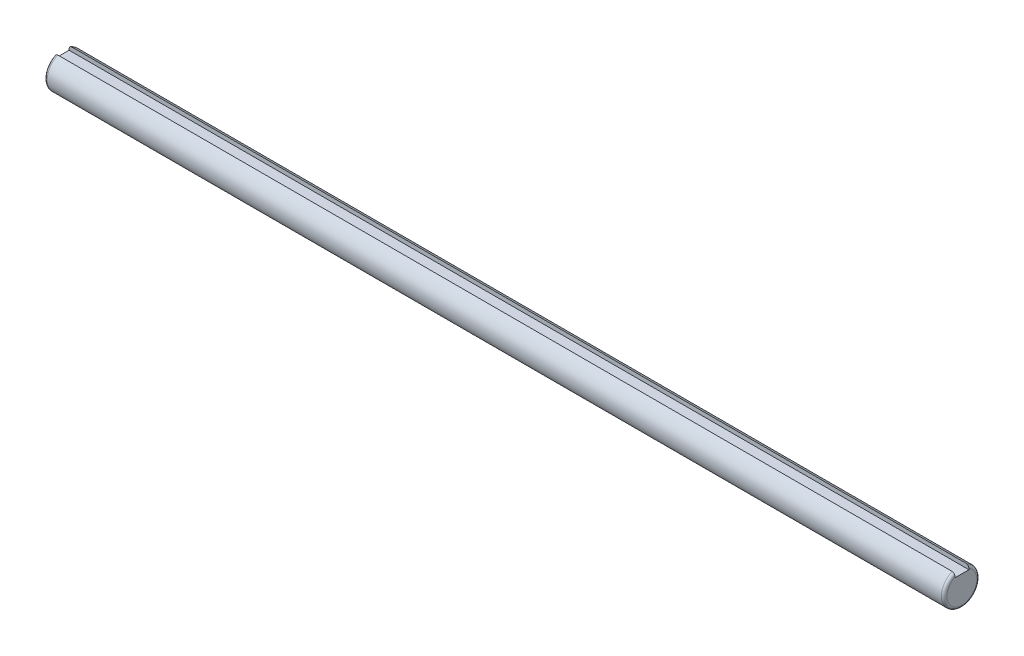
from build123d import *

# Parameters (mm, degrees)
BOSS_EXTRUDE1_DEPTH = 322.5
FILLET1_R           = 1


with BuildPart() as part:
    # Sketch2 → Boss-Extrude1 (new body)
    with BuildSketch(Plane(origin=(0, 0, 0), x_dir=(0, 0, -1), z_dir=(1, 0, 0))):
        with BuildLine():
            Line((2.5, 5.837165408), (2.5, 4.35))
            Line((2.5, 4.35), (-2.5, 4.35))
            Line((-2.5, 4.35), (-2.5, 5.837165408))
            ThreePointArc((-2.5, 5.837165408), (0, -6.35), (2.5, 5.837165408))
        make_face()
    extrude(amount=BOSS_EXTRUDE1_DEPTH)

    # Fillet1
    fillet1_edges = [part.edges().sort_by_distance(p)[0] for p in [
        (0, -6.35, 0),
        (322.5, -6.35, 0),
    ]]
    fillet(fillet1_edges, radius=FILLET1_R)


solid = part.part
